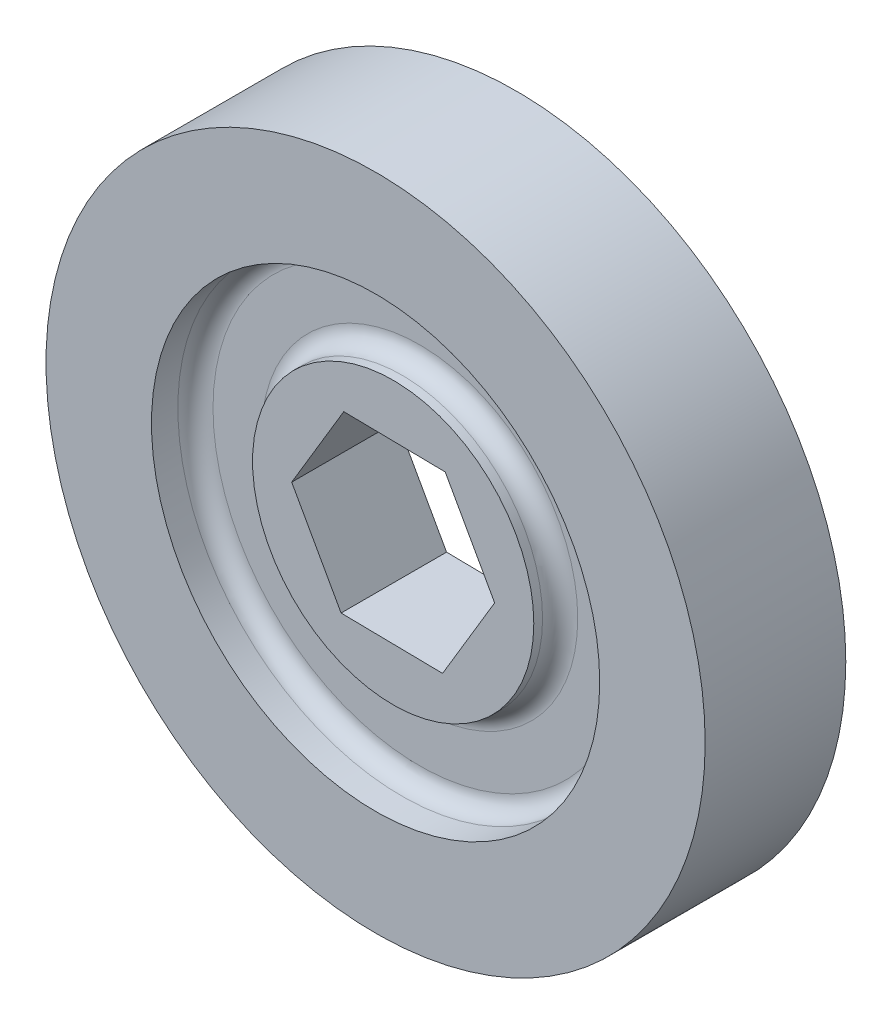
from build123d import *

# Parameters (mm, degrees)
SKETCH1_R           = 23.8125
BOSS_EXTRUDE1_DEPTH = 10.16
SKETCH2_R           = 16.1925
SKETCH2_R_2         = 10.16
CUT_EXTRUDE1_DEPTH  = 3.175
SKETCH3_R           = 16.1925
SKETCH3_R_2         = 10.16
CUT_EXTRUDE2_DEPTH  = 3.175
SKETCH4_R           = 10.16
CUT_EXTRUDE3_DEPTH  = 1.27
SKETCH7_R           = 10.16
CUT_EXTRUDE5_DEPTH  = 1.27
FILLET1_R           = 1.27


with BuildPart() as part:
    # Sketch1 → Boss-Extrude1 (new body)
    with BuildSketch(Plane.XY):
        Circle(SKETCH1_R)
        Polygon((3.569234353, -6.4049902), (7.331501401, -0.111447478), (3.762267048, 6.293542722), (-3.569234353, 6.4049902), (-7.331501401, 0.111447478), (-3.762267048, -6.293542722), align=None, mode=Mode.SUBTRACT)
    extrude(amount=BOSS_EXTRUDE1_DEPTH)

    # Sketch2 → Cut-Extrude1 (cut)
    with BuildSketch(Plane.XY.offset(10.16)):
        Circle(SKETCH2_R)
        Circle(SKETCH2_R_2, mode=Mode.SUBTRACT)
    extrude(amount=-CUT_EXTRUDE1_DEPTH, mode=Mode.SUBTRACT)

    # Sketch3 → Cut-Extrude2 (cut)
    with BuildSketch(Plane(origin=(0, 0, 0), x_dir=(-1, 0, 0), z_dir=(0, 0, -1))):
        Circle(SKETCH3_R)
        Circle(SKETCH3_R_2, mode=Mode.SUBTRACT)
    extrude(amount=-CUT_EXTRUDE2_DEPTH, mode=Mode.SUBTRACT)

    # Sketch4 → Cut-Extrude3 (cut)
    with BuildSketch(Plane(origin=(0, 0, 0), x_dir=(-1, 0, 0), z_dir=(0, 0, -1))):
        Circle(SKETCH4_R)
    extrude(amount=-CUT_EXTRUDE3_DEPTH, mode=Mode.SUBTRACT)

    # Sketch7 → Cut-Extrude5 (cut)
    with BuildSketch(Plane.XY.offset(10.16)):
        Circle(SKETCH7_R)
    extrude(amount=-CUT_EXTRUDE5_DEPTH, mode=Mode.SUBTRACT)

    # Fillet1
    fillet1_edges = [part.edges().sort_by_distance(p)[0] for p in [
        (-16.1925, 0, 6.985),
        (-10.16, 0, 6.985),
        (16.1925, 0, 3.175),
        (10.16, 0, 3.175),
    ]]
    fillet(fillet1_edges, radius=FILLET1_R)


solid = part.part
